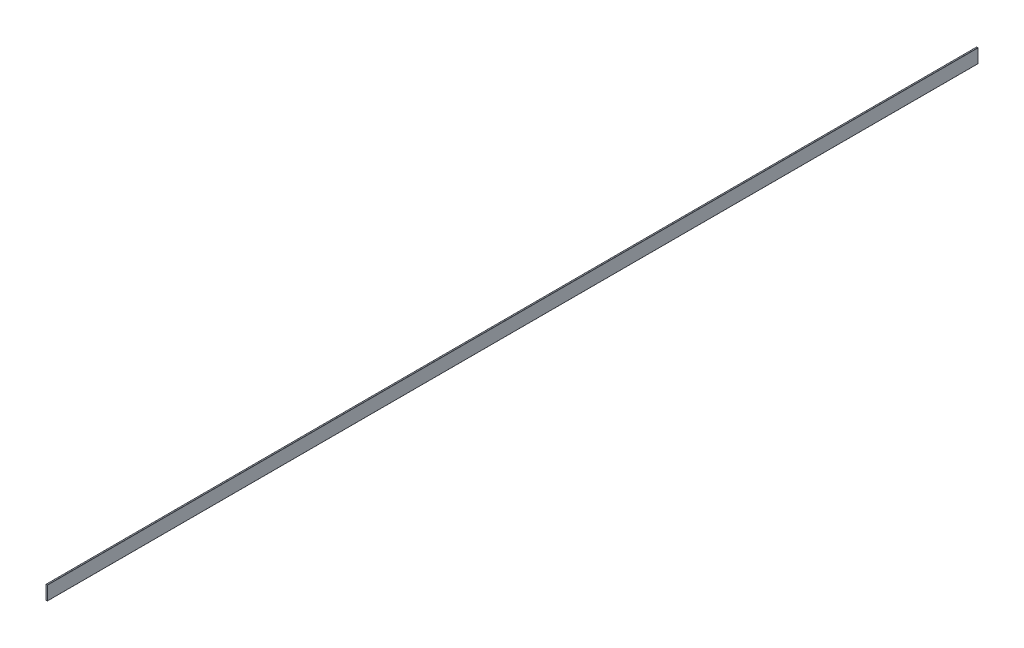
from build123d import *

# Parameters (mm, degrees)
BOSS_EXTRUDE1_DEPTH      = 1000
BOSS_EXTRUDE1_DEPTH_BACK = 1000


with BuildPart() as part:
    # Sketch1 → Boss-Extrude1 (new, two sides: drawn at the far end of the back side and taken through both)
    with BuildSketch(Plane.XY.offset(-BOSS_EXTRUDE1_DEPTH_BACK)):
        with BuildLine():
            Line((-1.15, -15), (1.15, -15))
            ThreePointArc((1.15, -15), (1.397487373, -14.897487373), (1.5, -14.65))
            Line((1.5, -14.65), (1.5, 14.65))
            ThreePointArc((1.5, 14.65), (1.397487373, 14.897487373), (1.15, 15))
            Line((1.15, 15), (-1.15, 15))
            ThreePointArc((-1.15, 15), (-1.397487373, 14.897487373), (-1.5, 14.65))
            Line((-1.5, 14.65), (-1.5, -14.65))
            ThreePointArc((-1.5, -14.65), (-1.397487373, -14.897487373), (-1.15, -15))
        make_face()
    extrude(amount=BOSS_EXTRUDE1_DEPTH + BOSS_EXTRUDE1_DEPTH_BACK)


solid = part.part
